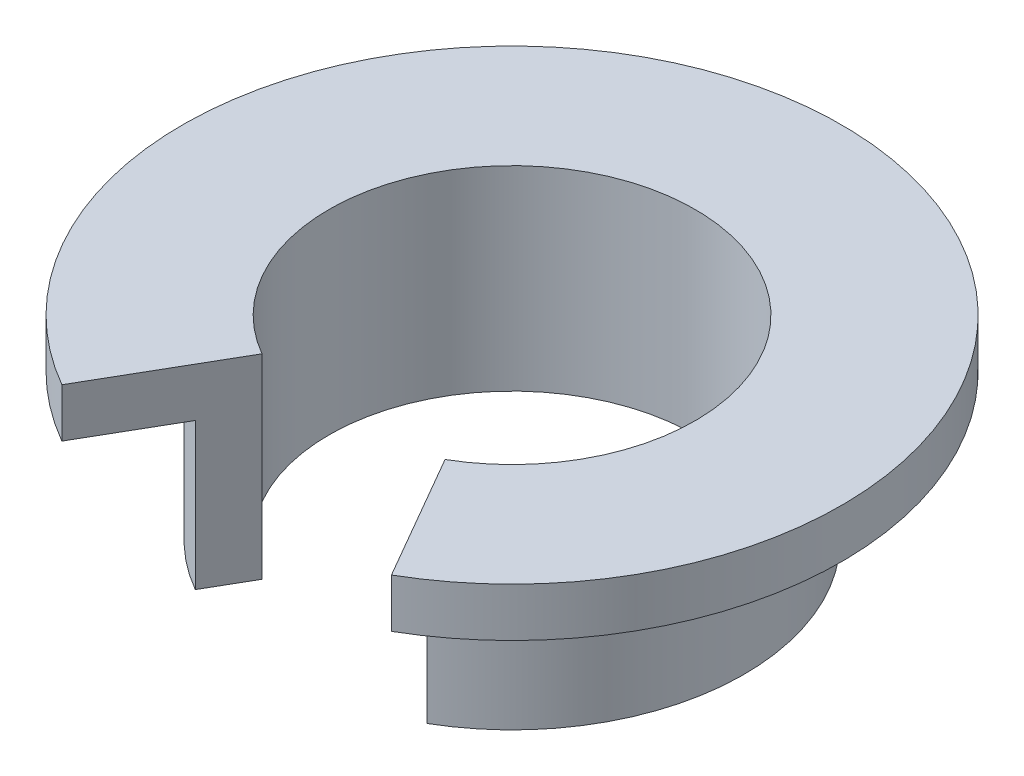
from build123d import *

# Parameters (mm, degrees)
CUT_EXTRUDE1_DEPTH = 10


with BuildPart() as part:
    # Sketch1 → Revolve1 (revolve)
    with BuildSketch(Plane.XY):
        Polygon((7.5, 0), (7.5, 8), (13.5, 8), (13.5, 6), (9.5, 6), (9.5, 0), align=None)
    revolve(axis=Axis((0, 0, 0), (0, 1, 0)))

    # Sketch2 → Cut-Extrude1 (cut)
    with BuildSketch(Plane(origin=(0, 0, 0), x_dir=(1, 0, 0), z_dir=(0, 1, 0))):
        Polygon((-9.091166867, -15.746362913), (0, 0), (8.625529774, -14.939855811), align=None)
    extrude(amount=CUT_EXTRUDE1_DEPTH, mode=Mode.SUBTRACT)


solid = part.part
